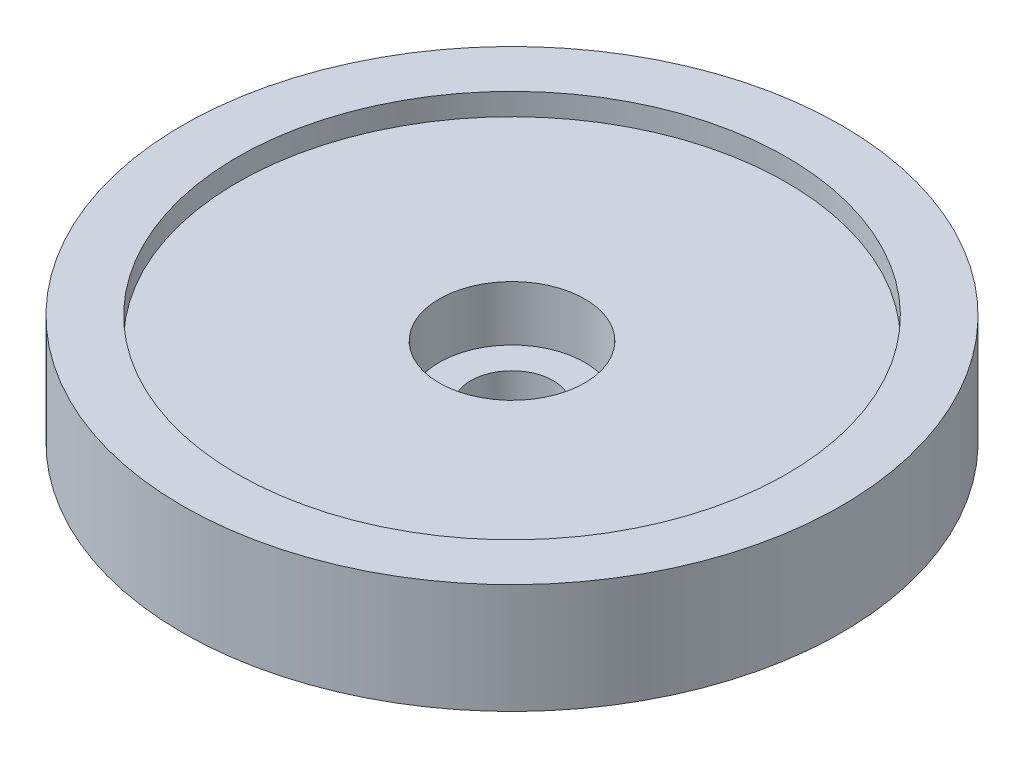
from build123d import *

# Parameters (mm, degrees)
SKETCH1_R               = 30
BOSS_EXTRUDE1_DEPTH     = 10
SKETCH2_R               = 25
CUT_EXTRUDE1_DEPTH      = 2
SKETCH3_R               = 6.625
CUT_EXTRUDE2_DEPTH      = 5
SKETCH4_R               = 3.75
CUT_EXTRUDE4_DEPTH      = 8
CUT_EXTRUDE4_DEPTH_BACK = 4


with BuildPart() as part:
    # Sketch1 → Boss-Extrude1 (new body)
    with BuildSketch(Plane(origin=(0, 0, 0), x_dir=(1, 0, 0), z_dir=(0, 1, 0))):
        Circle(SKETCH1_R)
    extrude(amount=BOSS_EXTRUDE1_DEPTH)

    # Sketch2 → Cut-Extrude1 (cut)
    with BuildSketch(Plane(origin=(0, 10, 0), x_dir=(1, 0, 0), z_dir=(0, 1, 0))):
        Circle(SKETCH2_R)
    extrude(amount=-CUT_EXTRUDE1_DEPTH, mode=Mode.SUBTRACT)

    # Sketch3 → Cut-Extrude2 (cut)
    with BuildSketch(Plane(origin=(0, 8, 0), x_dir=(1, 0, 0), z_dir=(0, 1, 0))):
        Circle(SKETCH3_R)
    extrude(amount=-CUT_EXTRUDE2_DEPTH, mode=Mode.SUBTRACT)

    # Sketch4 → Cut-Extrude4 (cut, two sides)
    with BuildSketch(Plane(origin=(0, 3, 0), x_dir=(1, 0, 0), z_dir=(0, 1, 0))) as cut_extrude4_sk:
        Circle(SKETCH4_R)
    extrude(amount=CUT_EXTRUDE4_DEPTH, mode=Mode.SUBTRACT)
    extrude(cut_extrude4_sk.sketch, amount=-CUT_EXTRUDE4_DEPTH_BACK, mode=Mode.SUBTRACT)


solid = part.part
